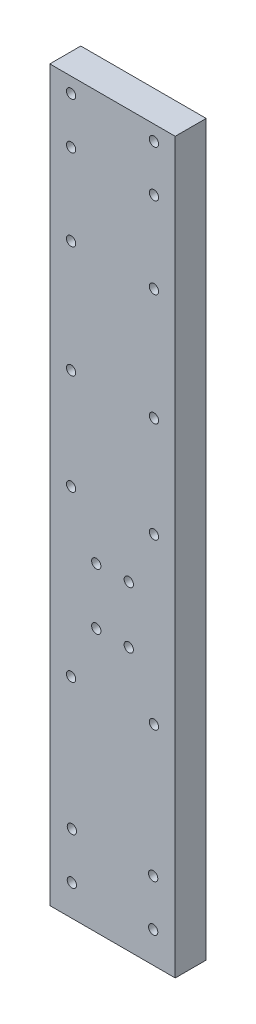
from build123d import *

# Parameters (mm, degrees)
SKETCH3_W           = 16.2
SKETCH3_H           = 94.16
SKETCH3_R           = 0.6
BOSS_EXTRUDE3_DEPTH = 4


with BuildPart() as part:
    # Sketch3 → Boss-Extrude3 (new body)
    with BuildSketch(Plane.XY):
        with Locations((8.1, 46.926448831)):
            Rectangle(SKETCH3_W, SKETCH3_H)
        with Locations((6, 33.846448831)):
            Circle(SKETCH3_R, mode=Mode.SUBTRACT)
        with Locations((10.2, 33.846448831)):
            Circle(SKETCH3_R, mode=Mode.SUBTRACT)
        with Locations((2.75, 86.061448831)):
            Circle(SKETCH3_R, mode=Mode.SUBTRACT)
        with Locations((10.2, 41.166448831)):
            Circle(SKETCH3_R, mode=Mode.SUBTRACT)
        with Locations((13.45, 48.106448831)):
            Circle(SKETCH3_R, mode=Mode.SUBTRACT)
        with Locations((2.75, 92.061448831)):
            Circle(SKETCH3_R, mode=Mode.SUBTRACT)
        with Locations((13.45, 86.061448831)):
            Circle(SKETCH3_R, mode=Mode.SUBTRACT)
        with Locations((2.75, 61.106448831)):
            Circle(SKETCH3_R, mode=Mode.SUBTRACT)
        with Locations((2.85, 9.846448831)):
            Circle(SKETCH3_R, mode=Mode.SUBTRACT)
        with Locations((13.35, 9.846448831)):
            Circle(SKETCH3_R, mode=Mode.SUBTRACT)
        with Locations((13.35, 3.846448831)):
            Circle(SKETCH3_R, mode=Mode.SUBTRACT)
        with Locations((2.85, 3.846448831)):
            Circle(SKETCH3_R, mode=Mode.SUBTRACT)
        with Locations((13.45, 61.106448831)):
            Circle(SKETCH3_R, mode=Mode.SUBTRACT)
        with Locations((2.75, 75.561448831)):
            Circle(SKETCH3_R, mode=Mode.SUBTRACT)
        with Locations((13.45, 26.846448831)):
            Circle(SKETCH3_R, mode=Mode.SUBTRACT)
        with Locations((13.45, 75.561448831)):
            Circle(SKETCH3_R, mode=Mode.SUBTRACT)
        with Locations((13.45, 92.061448831)):
            Circle(SKETCH3_R, mode=Mode.SUBTRACT)
        with Locations((2.75, 26.846448831)):
            Circle(SKETCH3_R, mode=Mode.SUBTRACT)
        with Locations((6, 41.106448831)):
            Circle(SKETCH3_R, mode=Mode.SUBTRACT)
        with Locations((2.75, 48.106448831)):
            Circle(SKETCH3_R, mode=Mode.SUBTRACT)
    extrude(amount=BOSS_EXTRUDE3_DEPTH)


solid = part.part
